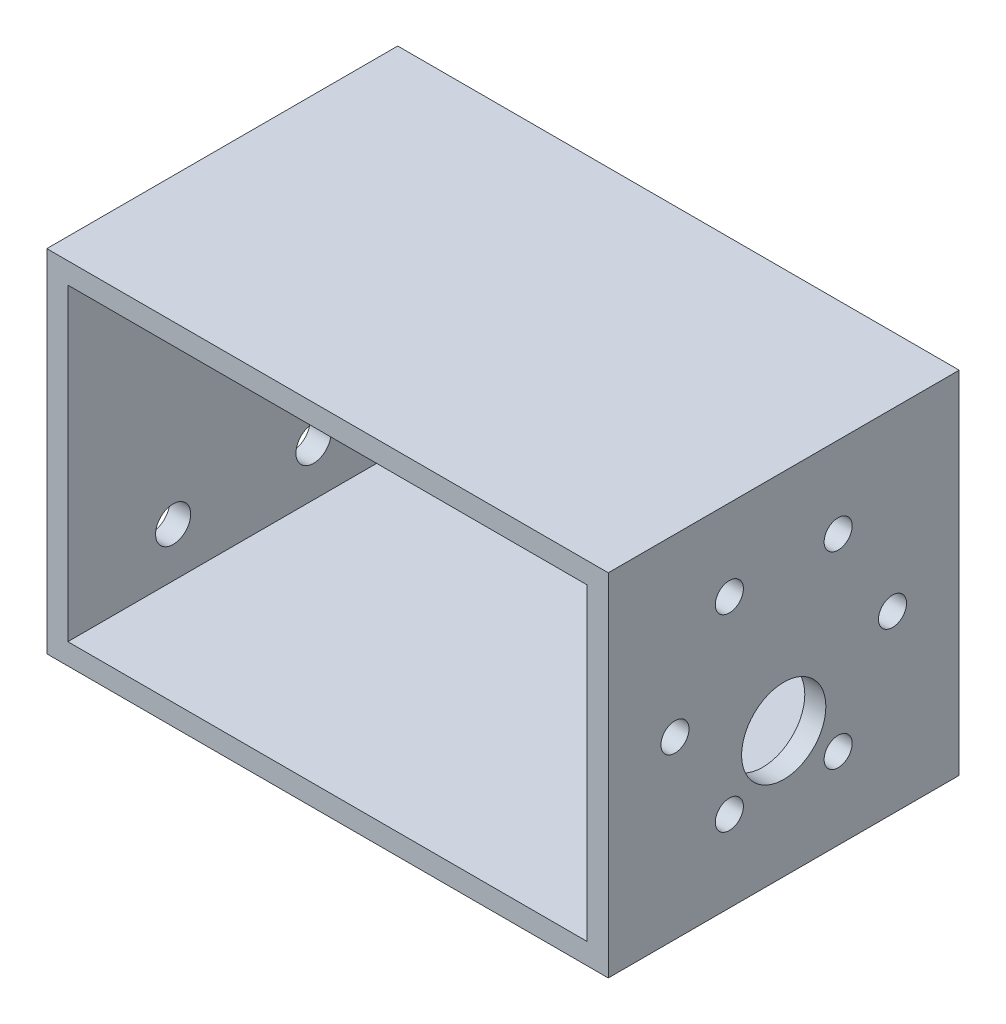
from build123d import *

# Parameters (mm, degrees)
SKETCH1_W           = 80
SKETCH1_H           = 50
SKETCH1_W_2         = 74
SKETCH1_H_2         = 44
BOSS_EXTRUDE1_DEPTH = 50
SKETCH2_R           = 2
SKETCH2_R_2         = 6
CUT_EXTRUDE1_DEPTH  = 3
CUT_EXTRUDE2_REACH  = 5
SKETCH3_R           = 2.5


with BuildPart() as part:
    # Sketch1 → Boss-Extrude1 (new body)
    with BuildSketch(Plane(origin=(0, 0, 0), x_dir=(1, 0, 0), z_dir=(0, 0, -1))):
        with Locations((40, 25)):
            Rectangle(SKETCH1_W, SKETCH1_H)
        with Locations((40, 25)):
            Rectangle(SKETCH1_W_2, SKETCH1_H_2, mode=Mode.SUBTRACT)
    extrude(amount=BOSS_EXTRUDE1_DEPTH)

    # Sketch2 → Cut-Extrude1 (cut)
    with BuildSketch(Plane(origin=(80, 0, 0), x_dir=(0, 0, -1), z_dir=(1, 0, 0))):
        with Locations((9.5, -25)):
            Circle(SKETCH2_R)
        with Locations((17.25, -38.423393759)):
            Circle(SKETCH2_R)
        with Locations((32.75, -38.423393759)):
            Circle(SKETCH2_R)
        with Locations((40.5, -25)):
            Circle(SKETCH2_R)
        with Locations((32.75, -11.576606241)):
            Circle(SKETCH2_R)
        with Locations((17.25, -11.576606241)):
            Circle(SKETCH2_R)
        with Locations((25, -32)):
            Circle(SKETCH2_R_2)
    extrude(amount=-CUT_EXTRUDE1_DEPTH, mode=Mode.SUBTRACT)

    # Sketch3 → Cut-Extrude2 (cut, up to next)
    with BuildSketch(Plane(origin=(3, 0, 0), x_dir=(0, 0, -1), z_dir=(1, 0, 0)), mode=Mode.PRIVATE) as cut_extrude2_sk1:
        with Locations((15, -40)):
            Circle(SKETCH3_R)
    cut_extrude2_tool1 = extrude(cut_extrude2_sk1.sketch, amount=-CUT_EXTRUDE2_REACH, mode=Mode.PRIVATE) & part.part
    add(cut_extrude2_tool1.solids().sort_by_distance((3, -40, -15))[0], mode=Mode.SUBTRACT)
    # Sketch3 → Cut-Extrude2 (cut, up to next)
    with BuildSketch(Plane(origin=(3, 0, 0), x_dir=(0, 0, -1), z_dir=(1, 0, 0)), mode=Mode.PRIVATE) as cut_extrude2_sk2:
        with Locations((15, -10)):
            Circle(SKETCH3_R)
    cut_extrude2_tool2 = extrude(cut_extrude2_sk2.sketch, amount=-CUT_EXTRUDE2_REACH, mode=Mode.PRIVATE) & part.part
    add(cut_extrude2_tool2.solids().sort_by_distance((3, -10, -15))[0], mode=Mode.SUBTRACT)
    # Sketch3 → Cut-Extrude2 (cut, up to next)
    with BuildSketch(Plane(origin=(3, 0, 0), x_dir=(0, 0, -1), z_dir=(1, 0, 0)), mode=Mode.PRIVATE) as cut_extrude2_sk3:
        with Locations((35, -10)):
            Circle(SKETCH3_R)
    cut_extrude2_tool3 = extrude(cut_extrude2_sk3.sketch, amount=-CUT_EXTRUDE2_REACH, mode=Mode.PRIVATE) & part.part
    add(cut_extrude2_tool3.solids().sort_by_distance((3, -10, -35))[0], mode=Mode.SUBTRACT)
    # Sketch3 → Cut-Extrude2 (cut, up to next)
    with BuildSketch(Plane(origin=(3, 0, 0), x_dir=(0, 0, -1), z_dir=(1, 0, 0)), mode=Mode.PRIVATE) as cut_extrude2_sk4:
        with Locations((35, -40)):
            Circle(SKETCH3_R)
    cut_extrude2_tool4 = extrude(cut_extrude2_sk4.sketch, amount=-CUT_EXTRUDE2_REACH, mode=Mode.PRIVATE) & part.part
    add(cut_extrude2_tool4.solids().sort_by_distance((3, -40, -35))[0], mode=Mode.SUBTRACT)


solid = part.part
